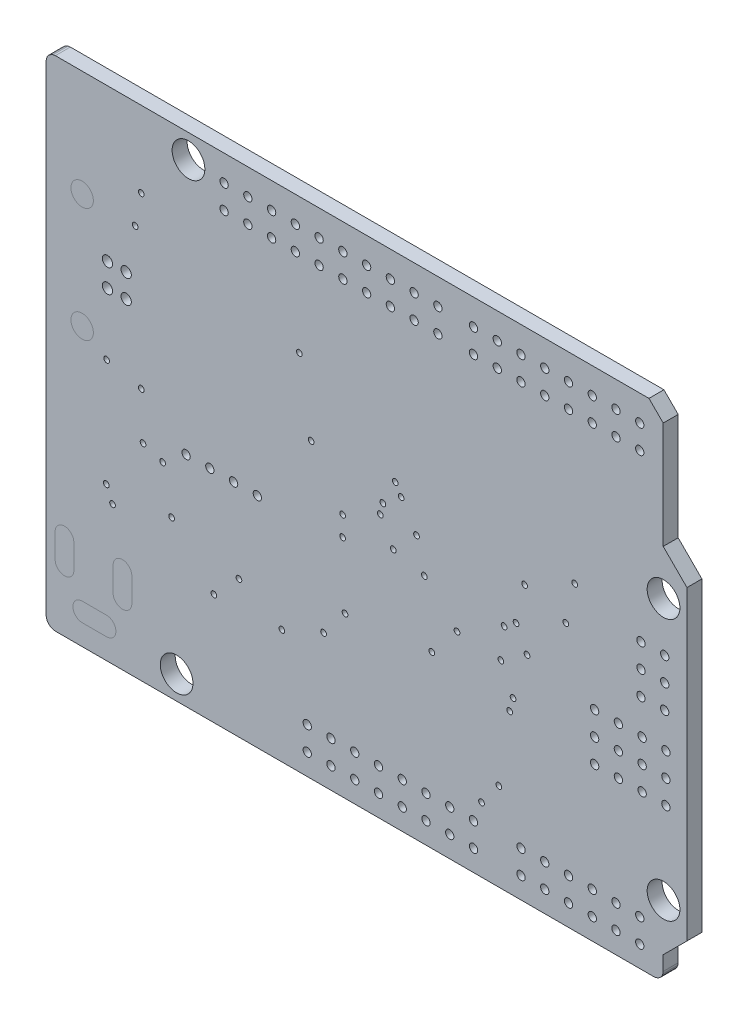
from build123d import *

# Parameters (mm, degrees)
SZKIC1_R                      = 1.7500092
DODANIE_WYCI_GNI_CIE1_DEPTH   = 1.6
SZKIC2_R                      = 0.4445
SZKIC2_R_2                    = 0.5500116
SZKIC2_R_3                    = 0.3050032
WYTNIJ_WYCI_GNI_CIE1_DEPTH    = 2.6
DODANIE_WYCI_GNI_CIE2_DEPTH   = 1.6
DODANIE_WYCI_GNI_CIE2_2_DEPTH = 1.6
DODANIE_WYCI_GNI_CIE2_3_DEPTH = 1.6
SZKIC4_R                      = 1.1999976
WYTNIJ_WYCI_GNI_CIE2_DEPTH    = 2.6
SZKIC5_R                      = 1.1999976
DODANIE_WYCI_GNI_CIE3_DEPTH   = 1.6
DODANIE_WYCI_GNI_CIE3_2_DEPTH = 1.6


with BuildPart() as part:
    # Szkic1 → Dodanie-wyciągnięcie1 (new body)
    with BuildSketch(Plane.XY):
        Polygon((-32.9977623, 52.284376), (-32.9977623, 0.9944862), (-32.9554205, 0.7405878), (-32.8707877, 0.5078222), (-32.7015221, 0.2962402), (-32.4899401, 0.1269746), (-32.2571745, 0.0423164), (-32.0032761, 0), (32.0032761, 0), (32.2571999, 0.0423164), (32.4899401, 0.1269746), (32.7015475, 0.2962402), (32.8708131, 0.5078222), (32.9554459, 0.7405878), (32.9977623, 0.9944862), (32.9977623, 2.539111), (35.5368733, 5.078222), (35.5368733, 37.8114814), (32.9977623, 40.3505924), (32.9977623, 51.7765538), (31.4742957, 53.3000204), (-32.0032761, 53.3000204), (-32.2571745, 53.2576786), (-32.4899401, 53.1518876), (-32.7015221, 53.0037802), (-32.8707877, 52.7921982), (-32.9554205, 52.5594326), align=None)
        with Locations((-19.0398273, 2.5200102)):
            Circle(SZKIC1_R, mode=Mode.SUBTRACT)
        with Locations((33.0301727, 7.6000102)):
            Circle(SZKIC1_R, mode=Mode.SUBTRACT)
        with Locations((33.0301727, 35.5400102)):
            Circle(SZKIC1_R, mode=Mode.SUBTRACT)
        with Locations((-17.7698273, 50.7800102)):
            Circle(SZKIC1_R, mode=Mode.SUBTRACT)
    extrude(amount=DODANIE_WYCI_GNI_CIE1_DEPTH)

    # Szkic2 → Wytnij-wyciągnięcie1 (cut, through all)
    with BuildSketch(Plane.XY.offset(1.6)):
        with Locations((-10.4038273, 23.3480102)):
            Circle(SZKIC2_R)
        with Locations((-12.9438273, 23.3480102)):
            Circle(SZKIC2_R)
        with Locations((-15.4838273, 23.3480102)):
            Circle(SZKIC2_R)
        with Locations((-18.0238273, 23.3480102)):
            Circle(SZKIC2_R)
        with Locations((-26.4317353, 34.544)):
            Circle(SZKIC2_R_2)
        with Locations((-26.4317353, 37.0440204)):
            Circle(SZKIC2_R_2)
        with Locations((-24.4317139, 34.544)):
            Circle(SZKIC2_R_2)
        with Locations((-24.4317139, 37.0440204)):
            Circle(SZKIC2_R_2)
        with Locations((-5.0698273, 4.8060102)):
            Circle(SZKIC2_R)
        with Locations((-5.0698273, 2.2660102)):
            Circle(SZKIC2_R)
        with Locations((-2.5298273, 2.2660102)):
            Circle(SZKIC2_R)
        with Locations((-2.5298273, 4.8060102)):
            Circle(SZKIC2_R)
        with Locations((0.0101727, 2.2660102)):
            Circle(SZKIC2_R)
        with Locations((0.0101727, 4.8060102)):
            Circle(SZKIC2_R)
        with Locations((2.5501727, 4.8060102)):
            Circle(SZKIC2_R)
        with Locations((2.5501727, 2.2660102)):
            Circle(SZKIC2_R)
        with Locations((5.0901727, 2.2660102)):
            Circle(SZKIC2_R)
        with Locations((5.0901727, 4.8060102)):
            Circle(SZKIC2_R)
        with Locations((7.6301727, 2.2660102)):
            Circle(SZKIC2_R)
        with Locations((7.6301727, 4.8060102)):
            Circle(SZKIC2_R)
        with Locations((10.1701727, 4.8060102)):
            Circle(SZKIC2_R)
        with Locations((10.1701727, 2.2660102)):
            Circle(SZKIC2_R)
        with Locations((12.7101727, 2.2660102)):
            Circle(SZKIC2_R)
        with Locations((12.7101727, 4.8060102)):
            Circle(SZKIC2_R)
        with Locations((17.7901727, 2.2660102)):
            Circle(SZKIC2_R)
        with Locations((17.7901727, 4.8060102)):
            Circle(SZKIC2_R)
        with Locations((20.3301727, 4.8060102)):
            Circle(SZKIC2_R)
        with Locations((20.3301727, 2.2660102)):
            Circle(SZKIC2_R)
        with Locations((22.8701727, 2.2660102)):
            Circle(SZKIC2_R)
        with Locations((22.8701727, 4.8060102)):
            Circle(SZKIC2_R)
        with Locations((25.4101727, 4.8060102)):
            Circle(SZKIC2_R)
        with Locations((25.4101727, 2.2660102)):
            Circle(SZKIC2_R)
        with Locations((27.9501727, 2.2660102)):
            Circle(SZKIC2_R)
        with Locations((27.9501727, 4.8060102)):
            Circle(SZKIC2_R)
        with Locations((30.4901727, 4.8060102)):
            Circle(SZKIC2_R)
        with Locations((30.4901727, 2.2660102)):
            Circle(SZKIC2_R)
        with Locations((33.2841727, 16.4900102)):
            Circle(SZKIC2_R)
        with Locations((30.7441727, 16.4900102)):
            Circle(SZKIC2_R)
        with Locations((28.2041727, 16.4900102)):
            Circle(SZKIC2_R)
        with Locations((25.6641727, 16.4900102)):
            Circle(SZKIC2_R)
        with Locations((25.6641727, 19.0300102)):
            Circle(SZKIC2_R)
        with Locations((28.2041727, 19.0300102)):
            Circle(SZKIC2_R)
        with Locations((30.7441727, 19.0300102)):
            Circle(SZKIC2_R)
        with Locations((33.2841727, 19.0300102)):
            Circle(SZKIC2_R)
        with Locations((33.2841727, 21.5700102)):
            Circle(SZKIC2_R)
        with Locations((30.7441727, 21.5700102)):
            Circle(SZKIC2_R)
        with Locations((28.2041727, 21.5700102)):
            Circle(SZKIC2_R)
        with Locations((25.6641727, 21.5700102)):
            Circle(SZKIC2_R)
        with Locations((30.6171727, 25.2530102)):
            Circle(SZKIC2_R)
        with Locations((33.1571727, 25.2530102)):
            Circle(SZKIC2_R)
        with Locations((33.1571727, 27.7930102)):
            Circle(SZKIC2_R)
        with Locations((30.6171727, 27.7930102)):
            Circle(SZKIC2_R)
        with Locations((30.6171727, 30.3330102)):
            Circle(SZKIC2_R)
        with Locations((33.1571727, 30.3330102)):
            Circle(SZKIC2_R)
        with Locations((-13.9598273, 47.9860102)):
            Circle(SZKIC2_R)
        with Locations((-11.4198273, 47.9860102)):
            Circle(SZKIC2_R)
        with Locations((-8.8798273, 47.9860102)):
            Circle(SZKIC2_R)
        with Locations((-6.3398273, 47.9860102)):
            Circle(SZKIC2_R)
        with Locations((-3.7998273, 47.9860102)):
            Circle(SZKIC2_R)
        with Locations((-1.2598273, 47.9860102)):
            Circle(SZKIC2_R)
        with Locations((1.2801727, 47.9860102)):
            Circle(SZKIC2_R)
        with Locations((1.2801727, 50.5260102)):
            Circle(SZKIC2_R)
        with Locations((-1.2598273, 50.5260102)):
            Circle(SZKIC2_R)
        with Locations((-3.7998273, 50.5260102)):
            Circle(SZKIC2_R)
        with Locations((-6.3398273, 50.5260102)):
            Circle(SZKIC2_R)
        with Locations((-8.8798273, 50.5260102)):
            Circle(SZKIC2_R)
        with Locations((-11.4198273, 50.5260102)):
            Circle(SZKIC2_R)
        with Locations((-13.9598273, 50.5260102)):
            Circle(SZKIC2_R)
        with Locations((3.8201727, 47.9860102)):
            Circle(SZKIC2_R)
        with Locations((3.8201727, 50.5260102)):
            Circle(SZKIC2_R)
        with Locations((6.3601727, 47.9860102)):
            Circle(SZKIC2_R)
        with Locations((6.3601727, 50.5260102)):
            Circle(SZKIC2_R)
        with Locations((8.9001727, 47.9860102)):
            Circle(SZKIC2_R)
        with Locations((8.9001727, 50.5260102)):
            Circle(SZKIC2_R)
        with Locations((20.3301727, 50.5260102)):
            Circle(SZKIC2_R)
        with Locations((17.7901727, 50.5260102)):
            Circle(SZKIC2_R)
        with Locations((15.2501727, 50.5260102)):
            Circle(SZKIC2_R)
        with Locations((12.7101727, 50.5260102)):
            Circle(SZKIC2_R)
        with Locations((12.7101727, 47.9860102)):
            Circle(SZKIC2_R)
        with Locations((15.2501727, 47.9860102)):
            Circle(SZKIC2_R)
        with Locations((17.7901727, 47.9860102)):
            Circle(SZKIC2_R)
        with Locations((20.3301727, 47.9860102)):
            Circle(SZKIC2_R)
        with Locations((22.8701727, 47.9860102)):
            Circle(SZKIC2_R)
        with Locations((22.8701727, 50.5260102)):
            Circle(SZKIC2_R)
        with Locations((25.4101727, 47.9860102)):
            Circle(SZKIC2_R)
        with Locations((25.4101727, 50.5260102)):
            Circle(SZKIC2_R)
        with Locations((27.9501727, 47.9860102)):
            Circle(SZKIC2_R)
        with Locations((27.9501727, 50.5260102)):
            Circle(SZKIC2_R)
        with Locations((30.4901727, 47.9860102)):
            Circle(SZKIC2_R)
        with Locations((30.4901727, 50.5260102)):
            Circle(SZKIC2_R)
        with Locations((-22.8168073, 45.1640702)):
            Circle(SZKIC2_R_3)
        with Locations((-23.4695873, 41.8087302)):
            Circle(SZKIC2_R_3)
        with Locations((-26.5201273, 27.8844502)):
            Circle(SZKIC2_R_3)
        with Locations((-22.8168073, 27.0462502)):
            Circle(SZKIC2_R_3)
        with Locations((-5.9105673, 38.8191502)):
            Circle(SZKIC2_R_3)
        with Locations((-4.6507273, 31.3032902)):
            Circle(SZKIC2_R_3)
        with Locations((4.3459527, 31.9865502)):
            Circle(SZKIC2_R_3)
        with Locations((4.9707927, 30.9070502)):
            Circle(SZKIC2_R_3)
        with Locations((2.7432127, 28.1943302)):
            Circle(SZKIC2_R_3)
        with Locations((3.0200727, 29.3703502)):
            Circle(SZKIC2_R_3)
        with Locations((6.6167127, 28.1867102)):
            Circle(SZKIC2_R_3)
        with Locations((4.1275127, 25.6467102)):
            Circle(SZKIC2_R_3)
        with Locations((-1.2877673, 26.1547102)):
            Circle(SZKIC2_R_3)
        with Locations((-1.2877673, 24.0592102)):
            Circle(SZKIC2_R_3)
        with Locations((-1.0312273, 17.1250102)):
            Circle(SZKIC2_R_3)
        with Locations((-22.6288473, 22.0957902)):
            Circle(SZKIC2_R_3)
        with Locations((-20.5308073, 21.3845902)):
            Circle(SZKIC2_R_3)
        with Locations((-25.8902073, 14.8263102)):
            Circle(SZKIC2_R_3)
        with Locations((-26.5582273, 16.3376102)):
            Circle(SZKIC2_R_3)
        with Locations((-19.5732273, 16.7516302)):
            Circle(SZKIC2_R_3)
        with Locations((-3.3223073, 14.1938502)):
            Circle(SZKIC2_R_3)
        with Locations((-7.7825473, 12.2431302)):
            Circle(SZKIC2_R_3)
        with Locations((-12.3723273, 14.6561302)):
            Circle(SZKIC2_R_3)
        with Locations((-15.0520273, 11.8875302)):
            Circle(SZKIC2_R_3)
        with Locations((7.4523727, 24.8567702)):
            Circle(SZKIC2_R_3)
        with Locations((10.9448727, 21.4480902)):
            Circle(SZKIC2_R_3)
        with Locations((8.2575527, 18.2019702)):
            Circle(SZKIC2_R_3)
        with Locations((13.5686927, 6.9319902)):
            Circle(SZKIC2_R_3)
        with Locations((15.4228927, 9.3932502)):
            Circle(SZKIC2_R_3)
        with Locations((16.5785927, 16.8837102)):
            Circle(SZKIC2_R_3)
        with Locations((16.9418127, 18.2807102)):
            Circle(SZKIC2_R_3)
        with Locations((15.6387927, 21.1255102)):
            Circle(SZKIC2_R_3)
        with Locations((15.9816927, 24.4529102)):
            Circle(SZKIC2_R_3)
        with Locations((18.4353327, 23.0305102)):
            Circle(SZKIC2_R_3)
        with Locations((17.2618527, 25.3952502)):
            Circle(SZKIC2_R_3)
        with Locations((18.1762527, 29.3932102)):
            Circle(SZKIC2_R_3)
        with Locations((22.5831527, 28.0520902)):
            Circle(SZKIC2_R_3)
        with Locations((23.5305727, 32.1719702)):
            Circle(SZKIC2_R_3)
        with BuildLine():
            Line((-30.0295945, 9.2181426), (-30.0295945, 6.6181478))
            ThreePointArc((-30.0295945, 6.6181478), (-31.0295925, 5.6181498), (-32.0295905, 6.6181478))
            Line((-32.0295905, 6.6181478), (-32.0295905, 9.2181426))
            ThreePointArc((-32.0295905, 9.2181426), (-31.0295925, 10.2181406), (-30.0295945, 9.2181426))
        make_face()
        with BuildLine():
            Line((-26.5297031, 4.2178732), (-29.1296979, 4.2178732))
            ThreePointArc((-29.1296979, 4.2178732), (-30.1296959, 3.2178752), (-29.1296979, 2.2178772))
            Line((-29.1296979, 2.2178772), (-26.5297031, 2.2178772))
            ThreePointArc((-26.5297031, 2.2178772), (-25.5297051, 3.2178752), (-26.5297031, 4.2178732))
        make_face()
        with BuildLine():
            Line((-23.8299625, 6.6181478), (-23.8299625, 9.2181426))
            ThreePointArc((-23.8299625, 9.2181426), (-24.8299605, 10.2181406), (-25.8299585, 9.2181426))
            Line((-25.8299585, 9.2181426), (-25.8299585, 6.6181478))
            ThreePointArc((-25.8299585, 6.6181478), (-24.8299605, 5.6181498), (-23.8299625, 6.6181478))
        make_face()
    extrude(amount=-WYTNIJ_WYCI_GNI_CIE1_DEPTH, mode=Mode.SUBTRACT)

    # Szkic4 → Wytnij-wyciągnięcie2 (cut, through all)
    with BuildSketch(Plane.XY.offset(1.6)):
        with Locations((-29.1418645, 29.6776902)):
            Circle(SZKIC4_R)
        with Locations((-29.1418645, 41.9103302)):
            Circle(SZKIC4_R)
    extrude(amount=-WYTNIJ_WYCI_GNI_CIE2_DEPTH, mode=Mode.SUBTRACT)


with BuildPart() as body_2:
    # Szkic3 → Dodanie-wyciągnięcie2 (new body)
    with BuildSketch(Plane.XY.offset(1.6)):
        with BuildLine():
            Line((-29.1296979, 2.2178772), (-26.5297031, 2.2178772))
            ThreePointArc((-26.5297031, 2.2178772), (-25.5297051, 3.2178752), (-26.5297031, 4.2178732))
            Line((-26.5297031, 4.2178732), (-29.1296979, 4.2178732))
            ThreePointArc((-29.1296979, 4.2178732), (-30.1296959, 3.2178752), (-29.1296979, 2.2178772))
        make_face()
    extrude(amount=-DODANIE_WYCI_GNI_CIE2_DEPTH)


with BuildPart() as body_3:
    # Szkic3 → Dodanie-wyci_gni_cie2 2 (new body)
    with BuildSketch(Plane.XY.offset(1.6)):
        with BuildLine():
            Line((-25.8299585, 9.2181426), (-25.8299585, 6.6181478))
            ThreePointArc((-25.8299585, 6.6181478), (-24.8299605, 5.6181498), (-23.8299625, 6.6181478))
            Line((-23.8299625, 6.6181478), (-23.8299625, 9.2181426))
            ThreePointArc((-23.8299625, 9.2181426), (-24.8299605, 10.2181406), (-25.8299585, 9.2181426))
        make_face()
    extrude(amount=-DODANIE_WYCI_GNI_CIE2_2_DEPTH)


with BuildPart() as body_4:
    # Szkic3 → Dodanie-wyci_gni_cie2 3 (new body)
    with BuildSketch(Plane.XY.offset(1.6)):
        with BuildLine():
            Line((-32.0295905, 9.2181426), (-32.0295905, 6.6181478))
            ThreePointArc((-32.0295905, 6.6181478), (-31.0295925, 5.6181498), (-30.0295945, 6.6181478))
            Line((-30.0295945, 6.6181478), (-30.0295945, 9.2181426))
            ThreePointArc((-30.0295945, 9.2181426), (-31.0295925, 10.2181406), (-32.0295905, 9.2181426))
        make_face()
    extrude(amount=-DODANIE_WYCI_GNI_CIE2_3_DEPTH)


with BuildPart() as body_5:
    # Szkic5 → Dodanie-wyciągnięcie3 (new body)
    with BuildSketch(Plane.XY.offset(1.6)):
        with Locations((-29.1418645, 41.9103302)):
            Circle(SZKIC5_R)
    extrude(amount=-DODANIE_WYCI_GNI_CIE3_DEPTH)


with BuildPart() as body_6:
    # Szkic5 → Dodanie-wyci_gni_cie3 2 (new body)
    with BuildSketch(Plane.XY.offset(1.6)):
        with Locations((-29.1418645, 29.6776902)):
            Circle(SZKIC5_R)
    extrude(amount=-DODANIE_WYCI_GNI_CIE3_2_DEPTH)


solid = Compound([part.part, body_2.part, body_3.part, body_4.part, body_5.part, body_6.part])
